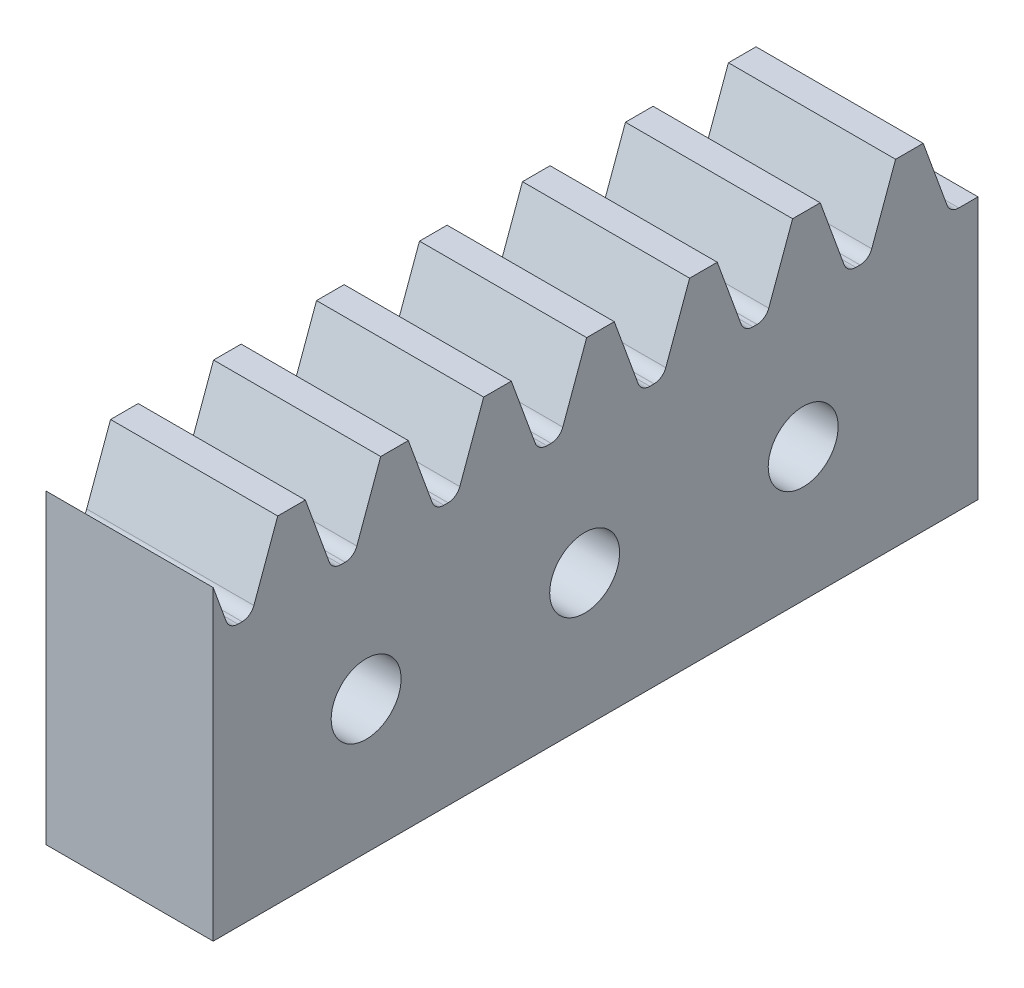
from build123d import *

# Parameters (mm, degrees)
ESQUISSE1_W                 = 24
ESQUISSE1_H                 = 30
MAIN_EXTRUSION_DEPTH        = 30
MAIN_RIDING_HOLE_DEPTH      = 31
ESQUISSE4_R                 = 2.25
TRACTORHOLE_DEPTH           = 8
IMPACTPIECE_DEPTH           = 4.5
CONG_1_R                    = 3
TEETH_DEPTH                 = 4.5
CONG_3_R                    = 0.57
TEETHREPETITION_COUNT       = 8
TEETHREPETITION_PITCH       = 4.71238898
CONG_3_OF_TEETHREPETITION_R = 0.57
ESQUISSE9_W                 = 55
ESQUISSE9_H                 = 15.375
BRACKET_DEPTH               = 0.675
BRACKETHOLE_START           = -8.5
ESQUISSE10_R                = 1.6
BRACKETHOLE_DEPTH           = 26
BRACKETHOLEREPETITION_COUNT = 5
BRACKETHOLEREPETITION_PITCH = 10
ESQUISSE11_W                = 7.5
ESQUISSE11_H                = 5.5
ESQUISSE11_H_2              = 7.6
RAILHOLE_DEPTH              = 20
TOPIMPACTCUT_DEPTH          = 17.5
ESQUISSE13_W                = 24
ESQUISSE13_H                = 50
MAKERBEAMMAINHOLE_DEPTH     = 81
SKETCH1_W                   = 24
SKETCH1_H                   = 45
KEEPONLYTRACTOR1_DEPTH      = 51


with BuildPart() as part:
    # Esquisse1 → Main Extrusion (new body)
    with BuildSketch(Plane.XY):
        Rectangle(ESQUISSE1_W, ESQUISSE1_H)
    extrude(amount=MAIN_EXTRUSION_DEPTH)

    # Esquisse3 → Main Riding Hole (cut, through all)
    with BuildSketch(Plane(origin=(0, 0, 0), x_dir=(-1, 0, 0), z_dir=(0, 0, -1))):
        Polygon((-5.2, -1.6), (-5.2, -5.4), (-4.2, -5.4), (-4.2, -8.2), (-5.2, -8.2), (-5.2, -12), (-1.4, -12), (-1.4, -11), (1.4, -11), (1.4, -12), (5.2, -12), (5.2, -8.2), (4.2, -8.2), (4.2, -5.4), (5.2, -5.4), (5.2, -1.6), (1.4, -1.6), (1.4, -2.6), (-1.4, -2.6), (-1.4, -1.6), align=None)
    extrude(amount=-MAIN_RIDING_HOLE_DEPTH, mode=Mode.SUBTRACT)

    # Esquisse4 → TractorHole (cut)
    with BuildSketch(Plane.ZY.offset(12)):
        with Locations((5, -6.8)):
            Circle(ESQUISSE4_R)
    tractorhole = extrude(amount=-TRACTORHOLE_DEPTH, mode=Mode.SUBTRACT)

    # TractorHoleSymetry: TractorHole across plane
    add(tractorhole.mirror(Plane(origin=(0, 0, 0), x_dir=(0, 0, 1), z_dir=(1, 0, 0))), mode=Mode.SUBTRACT)

    # Esquisse5 → ImpactPiece (add, symmetric)
    with BuildSketch(Plane(origin=(0, 0, 0), x_dir=(0, 0, -1), z_dir=(1, 0, 0))):
        Polygon((-45, 5), (-45, 35), (-25, 35), (-21.473460386, 15), (35, 15), (35, 3), (0, 3), (0, 5), align=None)
    extrude(amount=IMPACTPIECE_DEPTH, both=True)

    # Congé1
    cong_1_edges = [part.edges().sort_by_distance(p)[0] for p in [
        (4.5, 15, 25.736730193),
        (-4.5, 15, 25.736730193),
    ]]
    fillet(cong_1_edges, radius=CONG_1_R)

    # Esquisse8 → Teeth (add, symmetric)
    with BuildSketch(Plane(origin=(0, 0, 0), x_dir=(0, 0, -1), z_dir=(1, 0, 0))):
        Polygon((30, 15), (31.228399541, 18.375), (32.492683328, 18.375), (33.721082869, 15), align=None)
    teeth = extrude(amount=TEETH_DEPTH, both=True)

    # Congé3
    cong_3_edges = [part.edges().sort_by_distance(p)[0] for p in [
        (0, 15, -30),
        (0, 15, -33.721082869),
    ]]
    fillet(cong_3_edges, radius=CONG_3_R)

    # TeethRepetition: Teeth ×8
    with Locations(*[(0, 0, i * TEETHREPETITION_PITCH) for i in range(1, TEETHREPETITION_COUNT)]):
        add(teeth)

    # Congé3 of TeethRepetition
    cong_3_of_teethrepetition_edges = [part.edges().sort_by_distance(p)[0] for p in [
        (0, 15, -25.28761102),
        (0, 15, -29.008693889),
        (0, 15, -20.57522204),
        (0, 15, -24.296304909),
        (0, 15, -15.86283306),
        (0, 15, -19.583915929),
        (0, 15, -11.15044408),
        (0, 15, -14.871526949),
        (0, 15, -6.4380551),
        (0, 15, -10.159137969),
        (0, 15, -1.72566612),
        (0, 15, -5.446748989),
        (0, 15, 2.98672286),
        (0, 15, -0.734360009),
    ]]
    fillet(cong_3_of_teethrepetition_edges, radius=CONG_3_OF_TEETHREPETITION_R)

    # Esquisse9 → Bracket (cut, symmetric)
    with BuildSketch(Plane(origin=(4.5, 0, 0), x_dir=(0, 0, -1), z_dir=(1, 0, 0))):
        with Locations((7.5, 10.6875)):
            Rectangle(ESQUISSE9_W, ESQUISSE9_H)
    bracket = extrude(amount=BRACKET_DEPTH, both=True, mode=Mode.SUBTRACT)

    # Esquisse10 → BracketHole (cut)
    with BuildSketch(Plane.ZY.offset(-4.5).offset(BRACKETHOLE_START)):
        with Locations((-27, 9.1)):
            Circle(ESQUISSE10_R)
    brackethole = extrude(amount=BRACKETHOLE_DEPTH, mode=Mode.SUBTRACT)

    # BracketHoleRepetition: BracketHole ×5
    with Locations(*[(0, 0, i * BRACKETHOLEREPETITION_PITCH) for i in range(1, BRACKETHOLEREPETITION_COUNT)]):
        add(brackethole, mode=Mode.SUBTRACT)

    # Symétrie1: Bracket across plane
    add(bracket.mirror(Plane(origin=(0, 0, 0), x_dir=(0, 0, 1), z_dir=(1, 0, 0))), mode=Mode.SUBTRACT)

    # Esquisse11 → RailHole (cut)
    with BuildSketch(Plane(origin=(0, 0, 0), x_dir=(-1, 0, 0), z_dir=(0, 0, -1))):
        with Locations((8.25, 3.15)):
            Rectangle(ESQUISSE11_W, ESQUISSE11_H)
        with Locations((8.25, 16.2)):
            Rectangle(ESQUISSE11_W, ESQUISSE11_H_2)
    extrude(amount=-RAILHOLE_DEPTH, mode=Mode.SUBTRACT)

    # Esquisse12 → TopImpactCut (cut, through all)
    with BuildSketch(Plane(origin=(4.5, 0, 0), x_dir=(0, 0, -1), z_dir=(1, 0, 0))):
        Polygon((-45, 30), (-40, 35), (-45, 35), align=None)
    extrude(amount=-TOPIMPACTCUT_DEPTH, mode=Mode.SUBTRACT)


with BuildPart() as body_2:
    # Symétrie2: mirrored copy
    add(part.part.mirror(Plane(origin=(12, 15, 30), x_dir=(0, 0, 1), z_dir=(-1, 0, 0))))

    # Sketch1 → KeepOnlyTractor1 (cut, through all)
    with BuildSketch(Plane(origin=(0, 35, 0), x_dir=(1, 0, 0), z_dir=(0, 1, 0))):
        with Locations((24, -22.5)):
            Rectangle(SKETCH1_W, SKETCH1_H)
    extrude(amount=-KEEPONLYTRACTOR1_DEPTH, mode=Mode.SUBTRACT)


with BuildPart() as part_1:
    add(part.part)

    # Esquisse13 → MakerBeamMainHole (cut, through all)
    with BuildSketch(Plane(origin=(0, 0, -35), x_dir=(-1, 0, 0), z_dir=(0, 0, -1))):
        with Locations((0, 10)):
            Rectangle(ESQUISSE13_W, ESQUISSE13_H)
    extrude(amount=-MAKERBEAMMAINHOLE_DEPTH, mode=Mode.SUBTRACT)


solid = body_2.part
